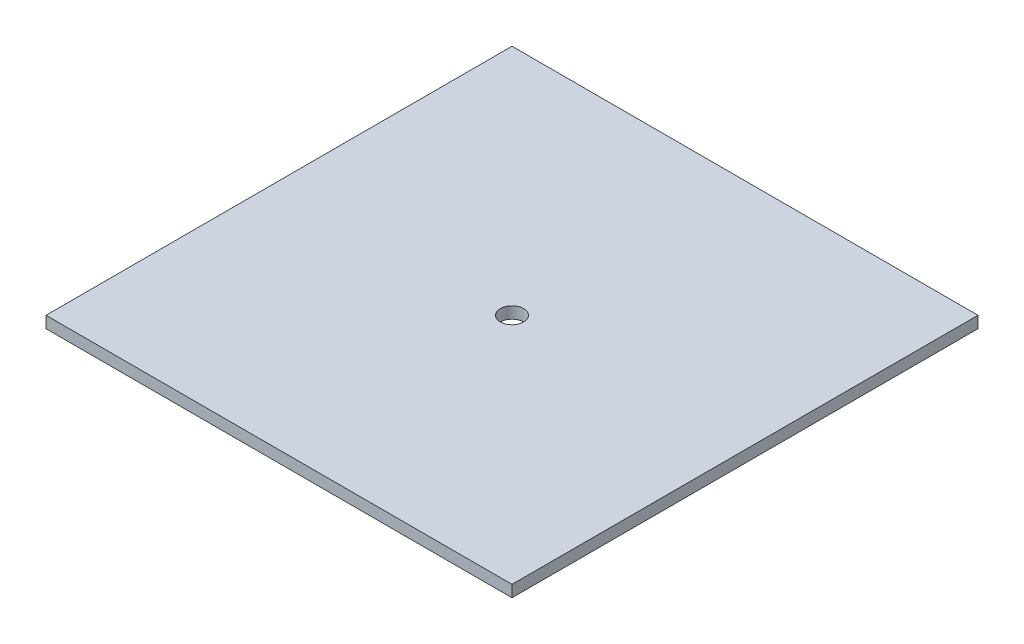
from build123d import *

# Parameters (mm, degrees)
SKETCH1_W           = 254
SKETCH1_H           = 254
SKETCH1_R           = 6.35
BOSS_EXTRUDE1_DEPTH = 6.35


with BuildPart() as part:
    # Sketch1 → Boss-Extrude1 (new body)
    with BuildSketch(Plane(origin=(0, 0, 0), x_dir=(1, 0, 0), z_dir=(0, 1, 0))):
        Rectangle(SKETCH1_W, SKETCH1_H)
        Circle(SKETCH1_R, mode=Mode.SUBTRACT)
    extrude(amount=BOSS_EXTRUDE1_DEPTH)


solid = part.part
